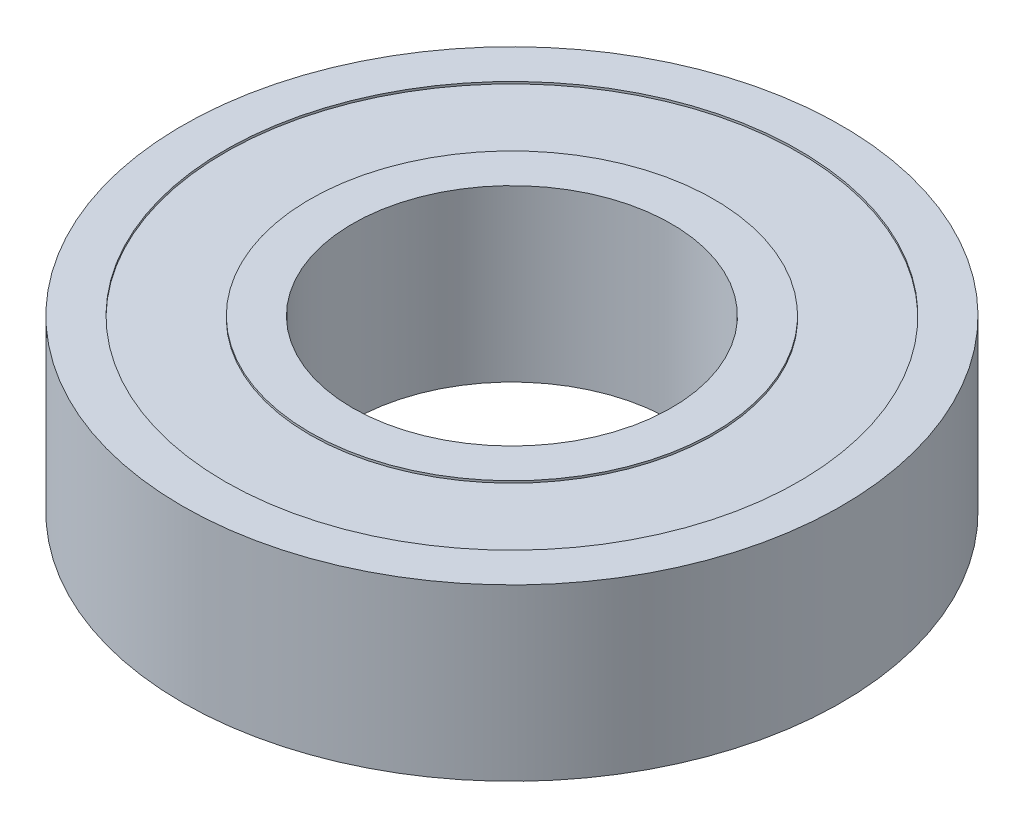
from build123d import *


with BuildPart() as part:
    # Skica1 → Rotovat1 (revolve)
    with BuildSketch(Plane.XY):
        Polygon((31, 0), (31, 16), (27, 16), (27, 15.8), (19, 15.8), (19, 16), (15, 16), (15, 0), (19, 0), (19, 0.2), (27, 0.2), (27, 0), align=None)
    revolve(axis=Axis((0, 16.084881291, 0), (0, -1, 0)))


solid = part.part
